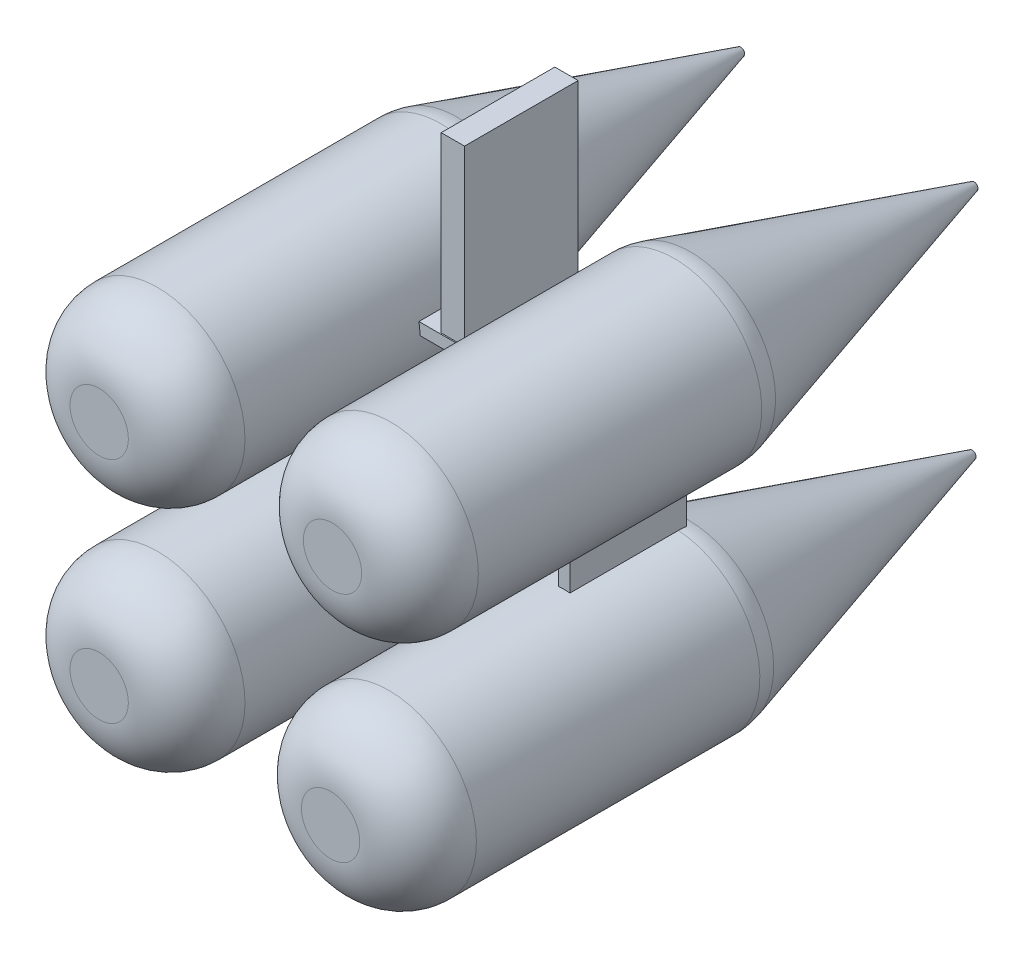
from build123d import *

# Parameters (mm, degrees)
IZIM2_R                               = 1.5
Y_KSEKLIK_EKSTR_ZYON1_DEPTH           = 6
Y_KSEKLIK_EKSTR_ZYON1_OTHER_WAY_DEPTH = 5
Y_KSEKLIK_EKSTR_ZYON1_OTHER_WAY_TAPER = 16
RADYUS1_R                             = 1
RADYUS2_R                             = 1
RADYUS3_R                             = 1
RADYUS4_R                             = 1
IZIM3_W                               = 1.366372993
IZIM3_H                               = 0.2
IZIM3_W_2                             = 0.2
IZIM3_H_2                             = 1.821830657
EKSTR_ZYON_NCE1_DEPTH                 = 2
IZIM4_W                               = 1.948226341
IZIM4_H                               = 3.106887173
Y_KSEKLIK_EKSTR_ZYON2_DEPTH           = 0.2
Y_KSEKLIK_EKSTR_ZYON2_DEPTH_BACK      = 0.2


with BuildPart() as part:
    # izim2 → Y_kseklik-Ekstr_zyon1 (new body)
    with BuildSketch(Plane.XY):
        with Locations((1.957696281, 2.49400279)):
            Circle(IZIM2_R)
        with Locations((1.924962477, -1.50586327)):
            Circle(IZIM2_R)
        with Locations((-2.042303717, 2.494135307)):
            Circle(IZIM2_R)
        with Locations((-2.042303717, -1.424442234)):
            Circle(IZIM2_R)
    extrude(amount=Y_KSEKLIK_EKSTR_ZYON1_DEPTH)

    # izim2 → Y_kseklik-Ekstr_zyon1 other way (add)
    with BuildSketch(Plane.XY):
        with Locations((1.957696281, 2.49400279)):
            Circle(IZIM2_R)
        with Locations((1.924962477, -1.50586327)):
            Circle(IZIM2_R)
        with Locations((-2.042303717, 2.494135307)):
            Circle(IZIM2_R)
        with Locations((-2.042303717, -1.424442234)):
            Circle(IZIM2_R)
    extrude(amount=-Y_KSEKLIK_EKSTR_ZYON1_OTHER_WAY_DEPTH, taper=Y_KSEKLIK_EKSTR_ZYON1_OTHER_WAY_TAPER)

    # Radyus1
    radyus1_edges = [part.edges().sort_by_distance(p)[0] for p in [
        (-3.542303717, 2.494135307, 0),
        (-3.542303717, 2.494135307, 6),
    ]]
    fillet(radyus1_edges, radius=RADYUS1_R)

    # Radyus2
    radyus2_edges = [part.edges().sort_by_distance(p)[0] for p in [
        (0.457696281, 2.49400279, 0),
        (0.457696281, 2.49400279, 6),
    ]]
    fillet(radyus2_edges, radius=RADYUS2_R)

    # Radyus3
    radyus3_edges = [part.edges().sort_by_distance(p)[0] for p in [
        (0.424962477, -1.50586327, 0),
        (0.424962477, -1.50586327, 6),
    ]]
    fillet(radyus3_edges, radius=RADYUS3_R)

    # Radyus4
    radyus4_edges = [part.edges().sort_by_distance(p)[0] for p in [
        (-3.542303717, -1.424442234, 0),
        (-3.542303717, -1.424442234, 6),
    ]]
    fillet(radyus4_edges, radius=RADYUS4_R)

    # izim3 → Ekstr_zyon-_nce1 (add)
    with BuildSketch(Plane.XY):
        with Locations((-0.086141829, 2.627534593)):
            Rectangle(IZIM3_W, IZIM3_H)
        with Locations((1.92848304, 0.315311653)):
            Rectangle(IZIM3_W_2, IZIM3_H_2)
        Polygon((0.748863888, -1.495674774), (-0.866926397, -1.506519004), (-0.868268648, -1.306523508), (0.747521636, -1.295679278), align=None)
        Polygon((-2.038103247, -0.248588312), (-2.059791708, 1.258759671), (-1.859812407, 1.261637071), (-1.838123947, -0.245710912), align=None)
    extrude(amount=EKSTR_ZYON_NCE1_DEPTH)

    # izim4 → Y_kseklik-Ekstr_zyon2 (add, two sides)
    with BuildSketch(Plane(origin=(0, 0, 0), x_dir=(0, 0, -1), z_dir=(1, 0, 0))) as y_kseklik_ekstr_zyon2_sk:
        with Locations((-1.005175918, 4.148063822)):
            Rectangle(IZIM4_W, IZIM4_H)
    extrude(amount=Y_KSEKLIK_EKSTR_ZYON2_DEPTH)
    extrude(y_kseklik_ekstr_zyon2_sk.sketch, amount=-Y_KSEKLIK_EKSTR_ZYON2_DEPTH_BACK)


solid = part.part
